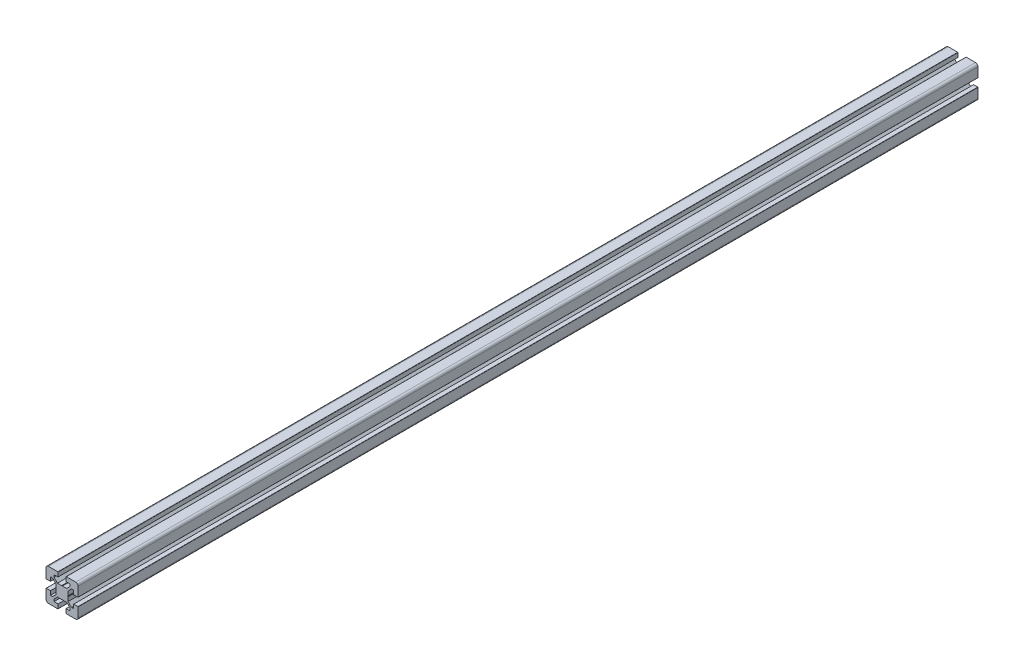
from build123d import *

# Parameters (mm, degrees)
EXTRUDE_1_DEPTH = 1120


with BuildPart() as part:
    # Model → ﾎﾞｽ - 押し出し1 (new body)
    with BuildSketch(Plane.XY):
        with BuildLine():
            Line((69.700000053, 55.000000195), (64.500000711, 55.000000195))
            Line((64.500000711, 55.000000195), (64.500000711, 60.000002187))
            Line((64.500000711, 60.000002187), (61.76777021, 60.000002187))
            Line((61.76777021, 60.000002187), (57.500000584, 55.732232559))
            Line((57.500000584, 55.732232559), (57.500000584, 50.519614724))
            Line((57.500000584, 50.519614724), (57.199999339, 50.000000177))
            Line((57.199999339, 50.000000177), (57.500000584, 49.48038563))
            Line((57.500000584, 49.48038563), (57.500000584, 44.267767795))
            Line((57.500000584, 44.267767795), (61.76777021, 39.999998167))
            Line((61.76777021, 39.999998167), (64.500000711, 39.999998167))
            Line((64.500000711, 39.999998167), (64.500000711, 45.000000159))
            Line((64.500000711, 45.000000159), (69.700000053, 45.000000159))
            ThreePointArc((69.700000053, 45.000000159), (69.9121326, 44.912131981), (70.000000778, 44.699999434))
            Line((70.000000778, 44.699999434), (70.000000778, 33.000000332))
            ThreePointArc((70.000000778, 33.000000332), (69.121321121, 30.878679988), (67.000000778, 30.000000332))
            Line((67.000000778, 30.000000332), (55.300001675, 30.000000332))
            ThreePointArc((55.300001675, 30.000000332), (55.087869129, 30.08786851), (55.000000951, 30.300001056))
            Line((55.000000951, 30.300001056), (55.000000951, 35.500000399))
            Line((55.000000951, 35.500000399), (60.000002943, 35.500000399))
            Line((60.000002943, 35.500000399), (60.000002943, 38.232230899))
            Line((60.000002943, 38.232230899), (55.732233316, 42.500000527))
            Line((55.732233316, 42.500000527), (50.519615481, 42.500000527))
            Line((50.519615481, 42.500000527), (50.000000936, 42.800001775))
            Line((50.000000936, 42.800001775), (49.480386391, 42.500000527))
            Line((49.480386391, 42.500000527), (44.267768556, 42.500000527))
            Line((44.267768556, 42.500000527), (39.999998929, 38.232230899))
            Line((39.999998929, 38.232230899), (39.999998929, 35.500000399))
            Line((39.999998929, 35.500000399), (45.000000921, 35.500000399))
            Line((45.000000921, 35.500000399), (45.000000921, 30.300001056))
            ThreePointArc((45.000000921, 30.300001056), (44.912132743, 30.08786851), (44.700000197, 30.000000332))
            Line((44.700000197, 30.000000332), (33.000001094, 30.000000332))
            ThreePointArc((33.000001094, 30.000000332), (30.87868075, 30.878679988), (30.000001094, 33.000000332))
            Line((30.000001094, 33.000000332), (30.000001094, 44.699999434))
            ThreePointArc((30.000001094, 44.699999434), (30.087869272, 44.912131981), (30.300001819, 45.000000159))
            Line((30.300001819, 45.000000159), (35.500001161, 45.000000159))
            Line((35.500001161, 45.000000159), (35.500001161, 39.999998167))
            Line((35.500001161, 39.999998167), (38.232231661, 39.999998167))
            Line((38.232231661, 39.999998167), (42.499994889, 44.267761396))
            Line((42.499994889, 44.267761396), (42.499994889, 49.48038563))
            Line((42.499994889, 49.48038563), (42.799996134, 50.000000177))
            Line((42.799996134, 50.000000177), (42.499994889, 50.519614724))
            Line((42.499994889, 50.519614724), (42.499994889, 55.732238958))
            Line((42.499994889, 55.732238958), (38.232231661, 60.000002187))
            Line((38.232231661, 60.000002187), (35.500001161, 60.000002187))
            Line((35.500001161, 60.000002187), (35.500001161, 55.000000195))
            Line((35.500001161, 55.000000195), (30.300001819, 55.000000195))
            ThreePointArc((30.300001819, 55.000000195), (30.087869272, 55.087868373), (30.000001094, 55.30000092))
            Line((30.000001094, 55.30000092), (30.000001094, 67.000000023))
            ThreePointArc((30.000001094, 67.000000023), (30.87868075, 69.121320366), (33.000001094, 70.000000023))
            Line((33.000001094, 70.000000023), (44.700000197, 70.000000023))
            ThreePointArc((44.700000197, 70.000000023), (44.912132743, 69.912131845), (45.000000921, 69.699999298))
            Line((45.000000921, 69.699999298), (45.000000921, 64.499999956))
            Line((45.000000921, 64.499999956), (39.999998929, 64.499999956))
            Line((39.999998929, 64.499999956), (39.999998929, 61.767769455))
            Line((39.999998929, 61.767769455), (44.267768556, 57.499999827))
            Line((44.267768556, 57.499999827), (49.480386391, 57.499999827))
            Line((49.480386391, 57.499999827), (50.000000936, 57.199998579))
            Line((50.000000936, 57.199998579), (50.519615481, 57.499999827))
            Line((50.519615481, 57.499999827), (55.732233316, 57.499999827))
            Line((55.732233316, 57.499999827), (60.000002943, 61.767769455))
            Line((60.000002943, 61.767769455), (60.000002943, 64.499999956))
            Line((60.000002943, 64.499999956), (55.000000951, 64.499999956))
            Line((55.000000951, 64.499999956), (55.000000951, 69.699999298))
            ThreePointArc((55.000000951, 69.699999298), (55.087869129, 69.912131845), (55.300001675, 70.000000023))
            Line((55.300001675, 70.000000023), (67.000000778, 70.000000023))
            ThreePointArc((67.000000778, 70.000000023), (69.121321121, 69.121320366), (70.000000778, 67.000000023))
            Line((70.000000778, 67.000000023), (70.000000778, 55.30000092))
            ThreePointArc((70.000000778, 55.30000092), (69.9121326, 55.087868373), (69.700000053, 55.000000195))
        make_face()
    extrude(amount=-EXTRUDE_1_DEPTH)


solid = part.part
